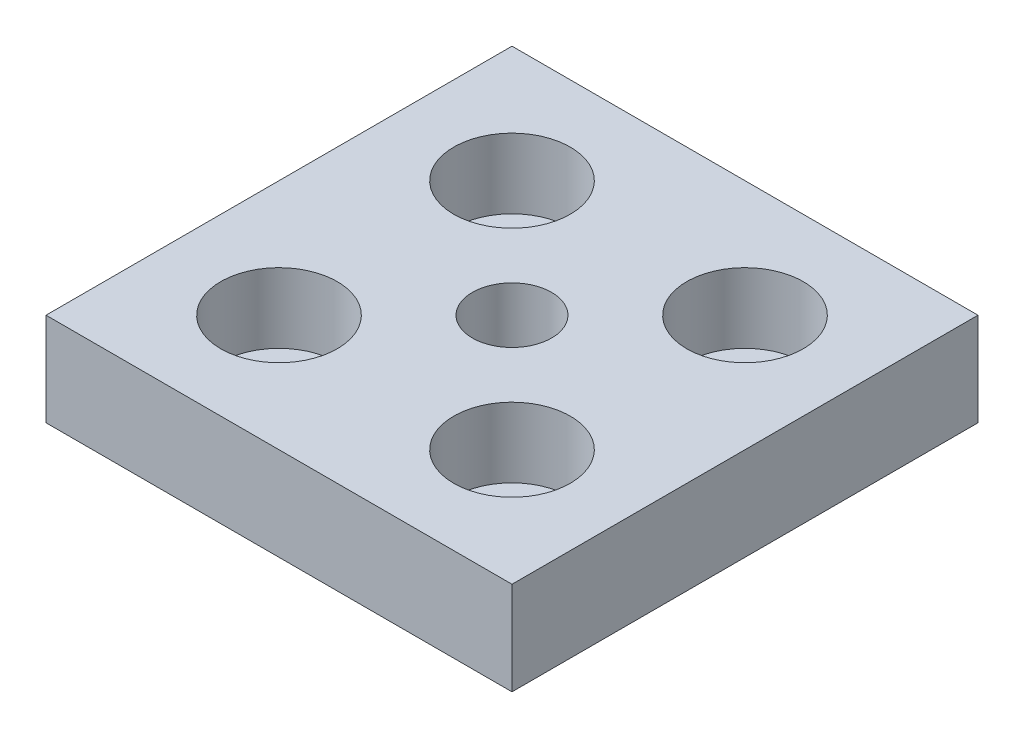
from build123d import *

# Parameters (mm, degrees)
SKETCH_1_W             = 60
SKETCH_1_H             = 60
EXTRUDE_1_DEPTH        = 12
HOLE_WIZARD_M121_D     = 10.2
HOLE_WIZARD_M121_DEPTH = 12
SKETCH_12_R            = 4.5
CUT_EXTRUDE_1_DEPTH    = 13
SKETCH_13_R            = 7.5
CUT_EXTRUDE_2_DEPTH    = 9


with BuildPart() as part:
    # Эскиз1 → Бобышка-Вытянуть1 (new body)
    with BuildSketch(Plane(origin=(0, 0, 0), x_dir=(1, 0, 0), z_dir=(0, 1, 0))):
        Rectangle(SKETCH_1_W, SKETCH_1_H)
    extrude(amount=EXTRUDE_1_DEPTH)

    # Отверстие обработанное метчиком M121
    with Locations(Plane(origin=(0, 12, 0), x_dir=(1, 0, 0), z_dir=(0, 1, 0))):
        with Locations((0, 0)):
            Hole(HOLE_WIZARD_M121_D / 2, depth=HOLE_WIZARD_M121_DEPTH)

    # Эскиз12 → Вырез-Вытянуть1 (cut, through all)
    with BuildSketch(Plane(origin=(0, 12, 0), x_dir=(1, 0, 0), z_dir=(0, 1, 0))):
        with Locations(Location((-15, 15, 0), (0, 0, 270))):  # turned: the seam where the file's is
            Circle(SKETCH_12_R)
        with Locations(Location((15, 15, 0), (0, 0, 270))):  # turned: the seam where the file's is
            Circle(SKETCH_12_R)
        with Locations(Location((15, -15, 0), (0, 0, 270))):  # turned: the seam where the file's is
            Circle(SKETCH_12_R)
        with Locations(Location((-15, -15, 0), (0, 0, 270))):  # turned: the seam where the file's is
            Circle(SKETCH_12_R)
    extrude(amount=-CUT_EXTRUDE_1_DEPTH, mode=Mode.SUBTRACT)

    # Эскиз13 → Вырез-Вытянуть2 (cut)
    with BuildSketch(Plane(origin=(0, 12, 0), x_dir=(1, 0, 0), z_dir=(0, 1, 0))):
        with Locations(Location((-15, 15, 0), (0, 0, 270))):  # turned: the seam where the file's is
            Circle(SKETCH_13_R)
        with Locations(Location((15, 15, 0), (0, 0, 270))):  # turned: the seam where the file's is
            Circle(SKETCH_13_R)
        with Locations(Location((15, -15, 0), (0, 0, 270))):  # turned: the seam where the file's is
            Circle(SKETCH_13_R)
        with Locations(Location((-15, -15, 0), (0, 0, 270))):  # turned: the seam where the file's is
            Circle(SKETCH_13_R)
    extrude(amount=-CUT_EXTRUDE_2_DEPTH, mode=Mode.SUBTRACT)


solid = part.part
